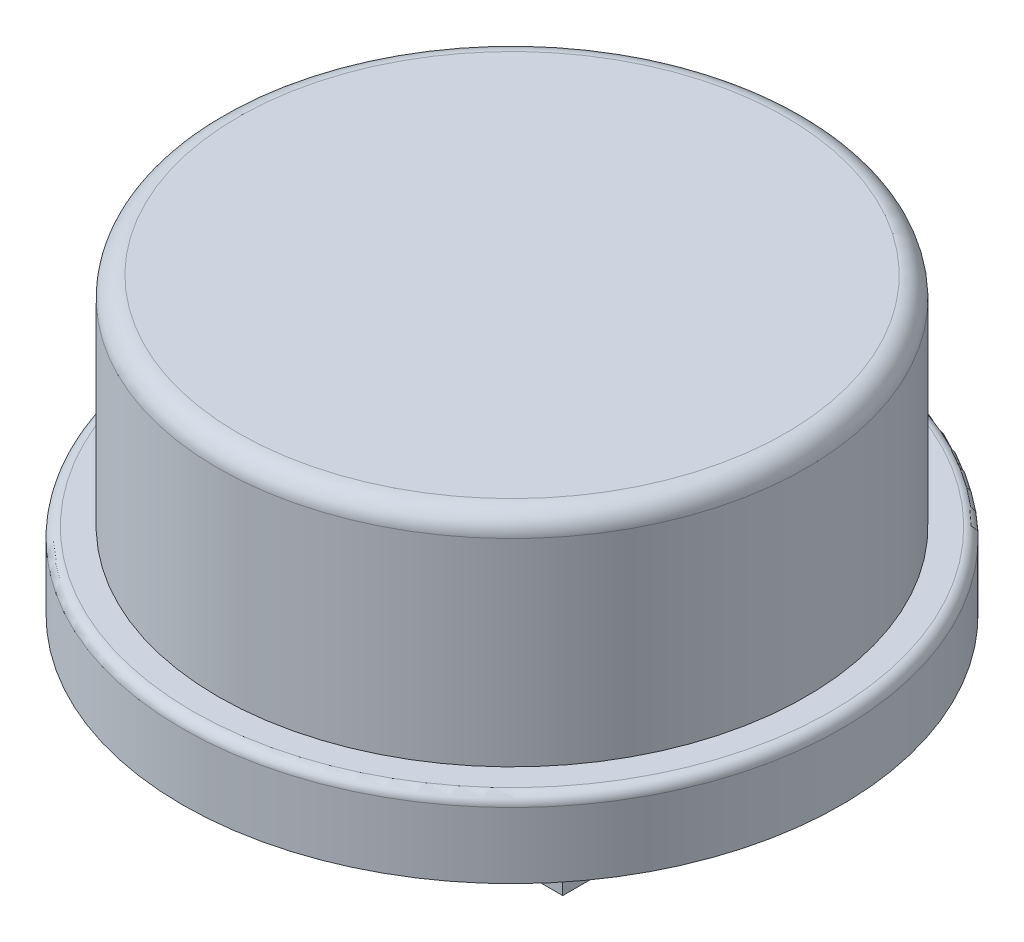
from build123d import *

# Parameters (mm, degrees)
SKETCH1_R           = 6.5
BOSS_EXTRUDE1_DEPTH = 1.5
SKETCH2_R           = 5.8
BOSS_EXTRUDE2_DEPTH = 4.3
FILLET1_R           = 0.4
SKETCH3_R           = 5
CUT_EXTRUDE1_DEPTH  = 4.8
BOSS_EXTRUDE3_DEPTH = 4.8
SKETCH5_W           = 2
SKETCH5_H           = 0.8
SKETCH5_W_2         = 1
SKETCH5_H_2         = 3.8
BOSS_EXTRUDE4_DEPTH = 7.2
CUT_EXTRUDE2_REACH  = 10.4
BOSS_EXTRUDE5_DEPTH = 3.8
FILLET2_R           = 0.1
FILLET3_R           = 0.2


with BuildPart() as part:
    # Sketch1 → Boss-Extrude1 (new body)
    with BuildSketch(Plane(origin=(0, 0, 0), x_dir=(1, 0, 0), z_dir=(0, 1, 0))):
        Circle(SKETCH1_R)
    extrude(amount=BOSS_EXTRUDE1_DEPTH)

    # Sketch2 → Boss-Extrude2 (add)
    with BuildSketch(Plane(origin=(0, 1.5, 0), x_dir=(1, 0, 0), z_dir=(0, 1, 0))):
        Circle(SKETCH2_R)
    extrude(amount=BOSS_EXTRUDE2_DEPTH)

    # Fillet1
    fillet1_edges = [part.edges().sort_by_distance(p)[0] for p in [
        (-5.8, 5.8, 0),
    ]]
    fillet(fillet1_edges, radius=FILLET1_R)

    # Sketch3 → Cut-Extrude1 (cut)
    with BuildSketch(Plane.XZ):
        Circle(SKETCH3_R)
    extrude(amount=-CUT_EXTRUDE1_DEPTH, mode=Mode.SUBTRACT)

    # Sketch4 → Boss-Extrude3 (add)
    with BuildSketch(Plane.XZ.offset(-4.8)):
        with BuildLine():
            Line((-4.990991885, 0.3), (-2.9, 0.3))
            Line((-2.9, 0.3), (-2.9, -0.3))
            Line((-2.9, -0.3), (-4.990991885, -0.3))
            ThreePointArc((-4.990991885, -0.3), (-5, 0), (-4.990991885, 0.3))
        make_face()
        with BuildLine():
            Line((2.9, 0.3), (2.9, -0.3))
            Line((2.9, -0.3), (4.990991885, -0.3))
            ThreePointArc((4.990991885, -0.3), (5, 0), (4.990991885, 0.3))
            Line((4.990991885, 0.3), (2.9, 0.3))
        make_face()
        with BuildLine():
            Line((-0.3, 4.990991885), (-0.3, 2.7))
            Line((-0.3, 2.7), (0.3, 2.7))
            Line((0.3, 2.7), (0.3, 4.990991885))
            ThreePointArc((0.3, 4.990991885), (0, 5), (-0.3, 4.990991885))
        make_face()
        with BuildLine():
            Line((0.3, -2.7), (-0.3, -2.7))
            Line((-0.3, -2.7), (-0.3, -4.990991885))
            ThreePointArc((-0.3, -4.990991885), (0, -5), (0.3, -4.990991885))
            Line((0.3, -4.990991885), (0.3, -2.7))
        make_face()
    extrude(amount=BOSS_EXTRUDE3_DEPTH)

    # Sketch5 → Boss-Extrude4 (add)
    with BuildSketch(Plane.XZ.offset(-4.8)):
        with Locations((0, 2.3)):
            Rectangle(SKETCH5_W, SKETCH5_H)
        with Locations((-2.4, 0)):
            Rectangle(SKETCH5_W_2, SKETCH5_H_2)
        with Locations((2.4, 0)):
            Rectangle(SKETCH5_W_2, SKETCH5_H_2)
        with Locations((0, -2.3)):
            Rectangle(SKETCH5_W, SKETCH5_H)
    extrude(amount=BOSS_EXTRUDE4_DEPTH)

    # Sketch6 → Cut-Extrude2 (cut, up to next)
    with BuildSketch(Plane.XY.offset(1.9), mode=Mode.PRIVATE) as cut_extrude2_sk1:
        Polygon((-1.9, -2.4), (-1.9, -1.9625), (-2.4, -2.4), align=None)
    cut_extrude2_tool1 = extrude(cut_extrude2_sk1.sketch, amount=-CUT_EXTRUDE2_REACH, mode=Mode.PRIVATE) & part.part
    add(cut_extrude2_tool1.solids().sort_by_distance((-2.066667, -2.254167, 1.9))[0], mode=Mode.SUBTRACT)
    # Sketch6 → Cut-Extrude2 (cut, up to next)
    with BuildSketch(Plane.XY.offset(1.9), mode=Mode.PRIVATE) as cut_extrude2_sk2:
        Polygon((1.9, -1.9625), (1.9, -2.4), (2.4, -2.4), align=None)
    cut_extrude2_tool2 = extrude(cut_extrude2_sk2.sketch, amount=-CUT_EXTRUDE2_REACH, mode=Mode.PRIVATE) & part.part
    add(cut_extrude2_tool2.solids().sort_by_distance((2.066667, -2.254167, 1.9))[0], mode=Mode.SUBTRACT)

    # Sketch6_3 → Boss-Extrude5 (add)
    with BuildSketch(Plane.XY.offset(1.9)):
        Polygon((-1.6, -1.7), (-1.9, -1.4), (-1.9, -1.9625), align=None)
        Polygon((1.6, -1.7), (1.9, -1.9625), (1.9, -1.4), align=None)
    extrude(amount=-BOSS_EXTRUDE5_DEPTH)

    # Fillet2
    fillet2_edges = [part.edges().sort_by_distance(p)[0] for p in [
        (-1.6, -1.7, 0),
        (1.6, -1.7, 0),
    ]]
    fillet(fillet2_edges, radius=FILLET2_R)

    # Fillet3
    fillet3_edges = [part.edges().sort_by_distance(p)[0] for p in [
        (-6.5, 1.5, 0),
    ]]
    fillet(fillet3_edges, radius=FILLET3_R)


solid = part.part
